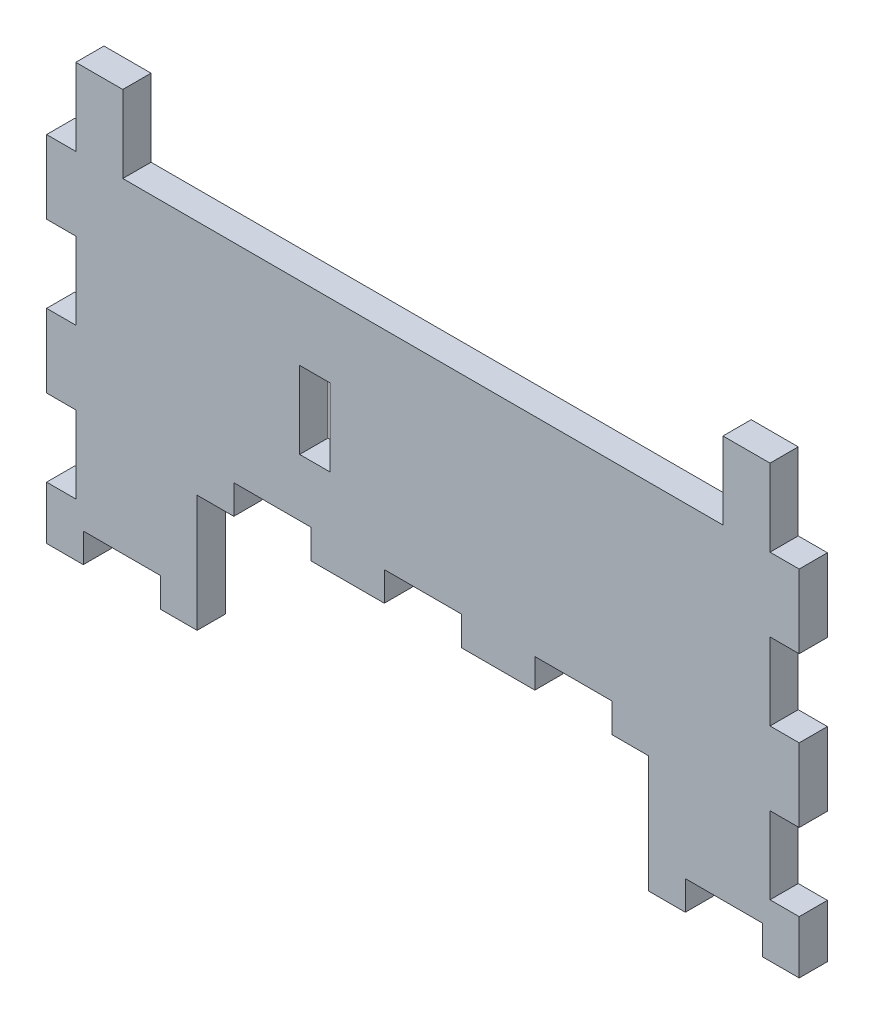
from build123d import *

# Parameters (mm, degrees)
BOSS_EXTRUDE1_DEPTH = 3
SKETCH3_W           = 8.2
SKETCH3_H           = 3.2
SKETCH3_W_2         = 3.2
SKETCH3_H_2         = 8.2
CUT_EXTRUDE3_DEPTH  = 4


with BuildPart() as part:
    # Sketch1 → Boss-Extrude1 (new body)
    with BuildSketch(Plane.XY):
        Polygon((0, 52.125), (11.2, 52.125), (11.2, 43.925), (16.5, 43.925), (16.5, 40.925), (63.5, 40.925), (63.5, 43.925), (68.8, 43.925), (68.8, 52.125), (80, 52.125), (80, 3.175), (64, 3.175), (64, 15.625), (16, 15.625), (16, 3.175), (0, 3.175), align=None)
    extrude(amount=-BOSS_EXTRUDE1_DEPTH)

    # Sketch3 → Cut-Extrude3 (cut, through all)
    with BuildSketch(Plane.XY):
        with Locations((40, 17.125)):
            Rectangle(SKETCH3_W, SKETCH3_H)
        with Locations((56, 17.125)):
            Rectangle(SKETCH3_W, SKETCH3_H)
        with Locations((24, 17.125)):
            Rectangle(SKETCH3_W, SKETCH3_H)
        with Locations((78.5, 12.925)):
            Rectangle(SKETCH3_W_2, SKETCH3_H_2)
        Polygon((3.1, 40.825), (3.1, 49.025), (8.1, 49.025), (8.1, 40.825), (71.9, 40.825), (71.9, 49.025), (76.9, 49.025), (76.9, 40.825), (80.1, 40.825), (80.1, 52.225), (68.7, 52.225), (68.7, 44.025), (11.3, 44.025), (11.3, 52.225), (-0.1, 52.225), (-0.1, 40.825), align=None)
        with Locations((28.5, 28.925)):
            Rectangle(SKETCH3_W_2, SKETCH3_H_2)
        with Locations((8, 4.675)):
            Rectangle(SKETCH3_W, SKETCH3_H)
        with Locations((1.5, 12.925)):
            Rectangle(SKETCH3_W_2, SKETCH3_H_2)
        with Locations((1.5, 28.925)):
            Rectangle(SKETCH3_W_2, SKETCH3_H_2)
        with Locations((78.5, 28.925)):
            Rectangle(SKETCH3_W_2, SKETCH3_H_2)
        with Locations((72, 4.675)):
            Rectangle(SKETCH3_W, SKETCH3_H)
    extrude(amount=-CUT_EXTRUDE3_DEPTH, mode=Mode.SUBTRACT)


solid = part.part
